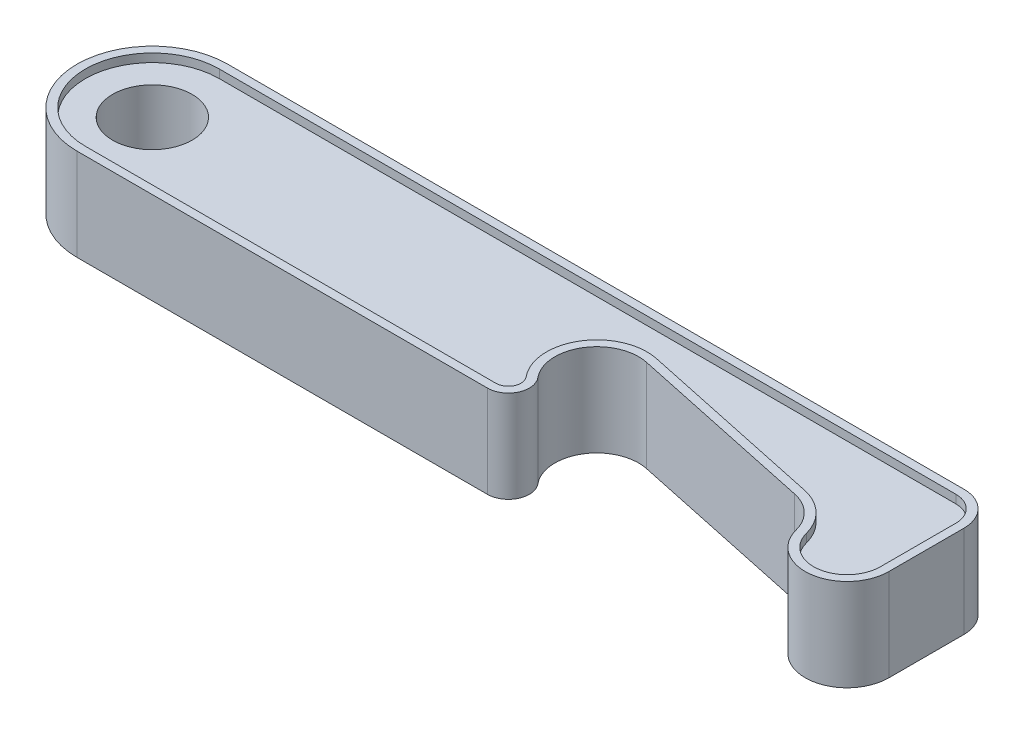
from build123d import *

# Parameters (mm, degrees)
SKETCH1_R           = 4.75
BOSS_EXTRUDE1_DEPTH = 9
BOSS_EXTRUDE2_DEPTH = 1
BOSS_EXTRUDE3_DEPTH = 1


with BuildPart() as part:
    # Sketch1 → Boss-Extrude1 (new body)
    with BuildSketch(Plane(origin=(0, 0, 0), x_dir=(1, 0, 0), z_dir=(0, 1, 0))):
        with BuildLine():
            Line((55.857100089, 3.173260641), (78.357100089, -1.609261996))
            ThreePointArc((78.357100089, -1.609261996), (80.775815642, -2.888858783), (82.158770817, -5.25))
            ThreePointArc((82.158770817, -5.25), (87.630021462, -8.960148481), (92, -4))
            Line((92, -4), (92, 5))
            ThreePointArc((92, 5), (90.828427125, 7.828427125), (88, 9))
            Line((88, 9), (0, 9))
            ThreePointArc((0, 9), (-9, 0), (0, -9))
            Line((0, -9), (49.040217235, -9))
            ThreePointArc((49.040217235, -9), (51.302454571, -7.564087513), (50.965992035, -4.905825787))
            ThreePointArc((50.965992035, -4.905825787), (50.540307373, 0.871975682), (55.857100089, 3.173260641))
        make_face()
        Circle(SKETCH1_R, mode=Mode.SUBTRACT)
    extrude(amount=BOSS_EXTRUDE1_DEPTH)

    # Sketch2 → Boss-Extrude2 (add)
    with BuildSketch(Plane(origin=(0, 9, 0), x_dir=(1, 0, 0), z_dir=(0, 1, 0))):
        with BuildLine():
            Line((0, -9), (49.040217235, -9))
            ThreePointArc((49.040217235, -9), (51.302454571, -7.564087513), (50.965992035, -4.905825787))
            ThreePointArc((50.965992035, -4.905825787), (50.540307373, 0.871975682), (55.857100089, 3.173260641))
            Line((55.857100089, 3.173260641), (78.357100089, -1.609261996))
            ThreePointArc((78.357100089, -1.609261996), (80.775815642, -2.888858783), (82.158770817, -5.25))
            ThreePointArc((82.158770817, -5.25), (87.630021462, -8.960148481), (92, -4))
            Line((92, -4), (92, 5))
            ThreePointArc((92, 5), (90.828427125, 7.828427125), (88, 9))
            Line((88, 9), (0, 9))
            ThreePointArc((0, 9), (-9, 0), (0, -9))
        make_face()
        with BuildLine():
            Line((88, 8), (0, 8))
            ThreePointArc((0, 8), (-8, 0), (0, -8))
            Line((0, -8), (49.040217235, -8))
            ThreePointArc((49.040217235, -8), (50.397559636, -7.138452508), (50.195682115, -5.543495472))
            ThreePointArc((50.195682115, -5.543495472), (49.68486052, 1.389866291), (56.065011779, 4.151408242))
            Line((56.065011779, 4.151408242), (78.565011779, -0.631114396))
            ThreePointArc((78.565011779, -0.631114396), (81.467470443, -2.166630539), (83.127016654, -5))
            ThreePointArc((83.127016654, -5), (87.50401717, -7.968118785), (91, -4))
            Line((91, -4), (91, 5))
            ThreePointArc((91, 5), (90.121320344, 7.121320344), (88, 8))
        make_face(mode=Mode.SUBTRACT)
    extrude(amount=BOSS_EXTRUDE2_DEPTH)

    # Sketch3 → Boss-Extrude3 (add)
    with BuildSketch(Plane.XZ):
        with BuildLine():
            Line((0, -9), (88, -9))
            ThreePointArc((88, -9), (90.828427125, -7.828427125), (92, -5))
            Line((92, -5), (92, 4))
            ThreePointArc((92, 4), (87.630021462, 8.960148481), (82.158770817, 5.25))
            ThreePointArc((82.158770817, 5.25), (80.775815642, 2.888858783), (78.357100089, 1.609261996))
            Line((78.357100089, 1.609261996), (55.857100089, -3.173260641))
            ThreePointArc((55.857100089, -3.173260641), (50.540307373, -0.871975682), (50.965992035, 4.905825787))
            ThreePointArc((50.965992035, 4.905825787), (51.302454571, 7.564087513), (49.040217235, 9))
            Line((49.040217235, 9), (0, 9))
            ThreePointArc((0, 9), (-9, 0), (0, -9))
        make_face()
        with BuildLine():
            Line((49.040217235, 8), (0, 8))
            ThreePointArc((0, 8), (-8, 0), (0, -8))
            Line((0, -8), (88, -8))
            ThreePointArc((88, -8), (90.121320344, -7.121320344), (91, -5))
            Line((91, -5), (91, 4))
            ThreePointArc((91, 4), (87.50401717, 7.968118785), (83.127016654, 5))
            ThreePointArc((83.127016654, 5), (81.467470443, 2.166630539), (78.565011779, 0.631114396))
            Line((78.565011779, 0.631114396), (56.065011779, -4.151408242))
            ThreePointArc((56.065011779, -4.151408242), (49.68486052, -1.389866291), (50.195682115, 5.543495472))
            ThreePointArc((50.195682115, 5.543495472), (50.397559636, 7.138452508), (49.040217235, 8))
        make_face(mode=Mode.SUBTRACT)
    extrude(amount=BOSS_EXTRUDE3_DEPTH)


solid = part.part
